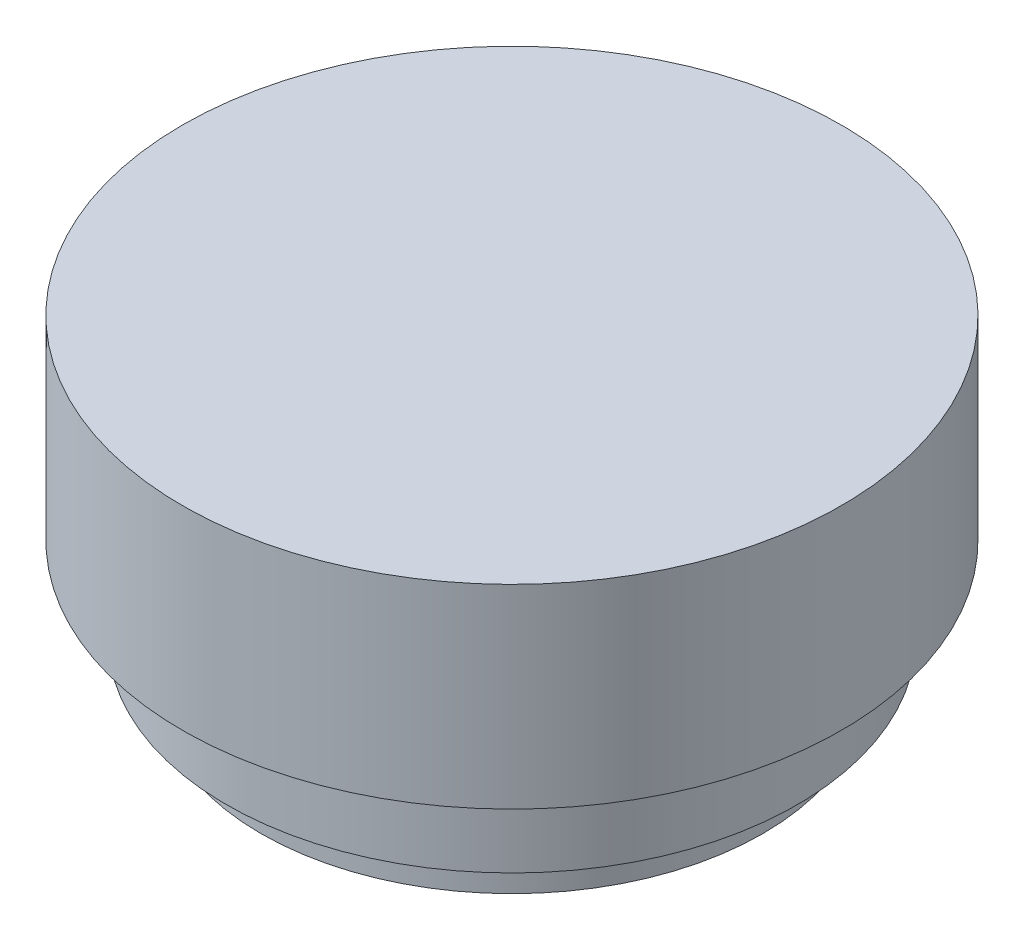
from build123d import *


with BuildPart() as part:
    # Sketch1 → Revolve1 (revolve)
    with BuildSketch(Plane.XY):
        Polygon((-29, 6.6), (-29, 11.5), (-33, 11.5), (-33, 21.5), (-38.1, 21.5), (-38.1, 44), (0, 44), (0, 6.6), align=None)
    revolve(axis=Axis((0, 44, 0), (0, -1, 0)))


solid = part.part
